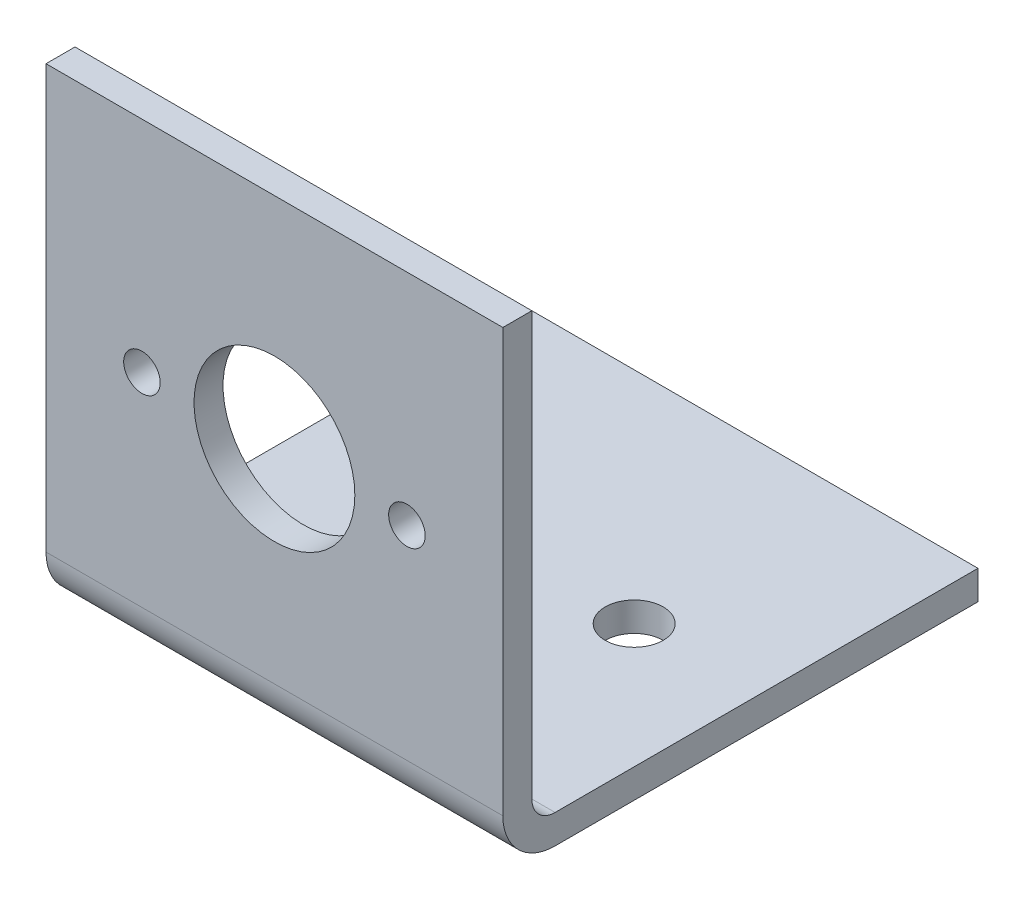
from build123d import *

# Parameters (mm, degrees)
BOSS_EXTRUDE1_DEPTH     = 50
FILLET1_R               = 2.54
FILLET2_R               = 5.715
SKETCH2_R               = 8.8
SKETCH2_R_2             = 2
CUT_EXTRUDE1_DEPTH      = 1
CUT_EXTRUDE1_DEPTH_BACK = 53
SKETCH4_R               = 3.175
CUT_EXTRUDE2_DEPTH      = 1
CUT_EXTRUDE2_DEPTH_BACK = 53


with BuildPart() as part:
    # Sketch1 → Boss-Extrude1 (new body)
    with BuildSketch(Plane(origin=(0, 0, 0), x_dir=(0, 0, -1), z_dir=(1, 0, 0))):
        Polygon((0, 0), (0, -52), (52, -52), (52, -48.825), (3.175, -48.825), (3.175, 0), align=None)
    extrude(amount=BOSS_EXTRUDE1_DEPTH)

    # Fillet1
    fillet1_edges = [part.edges().sort_by_distance(p)[0] for p in [
        (25, -48.825, -3.175),
    ]]
    fillet(fillet1_edges, radius=FILLET1_R)

    # Fillet2
    fillet2_edges = [part.edges().sort_by_distance(p)[0] for p in [
        (25, -52, 0),
    ]]
    fillet(fillet2_edges, radius=FILLET2_R)

    # Sketch2 → Cut-Extrude1 (cut, two sides)
    with BuildSketch(Plane.XY) as cut_extrude1_sk:
        with Locations((25, -24)):
            Circle(SKETCH2_R)
        with Locations((10.5, -24)):
            Circle(SKETCH2_R_2)
        with Locations((39.5, -24)):
            Circle(SKETCH2_R_2)
    extrude(amount=CUT_EXTRUDE1_DEPTH, mode=Mode.SUBTRACT)
    extrude(cut_extrude1_sk.sketch, amount=-CUT_EXTRUDE1_DEPTH_BACK, mode=Mode.SUBTRACT)

    # Sketch4 → Cut-Extrude2 (cut, two sides)
    with BuildSketch(Plane.XZ.offset(52)) as cut_extrude2_sk:
        with Locations((13.57, -27.94)):
            Circle(SKETCH4_R)
        with Locations((36.43, -27.94)):
            Circle(SKETCH4_R)
        with Locations((25, -12.7)):
            Circle(SKETCH4_R)
    extrude(amount=CUT_EXTRUDE2_DEPTH, mode=Mode.SUBTRACT)
    extrude(cut_extrude2_sk.sketch, amount=-CUT_EXTRUDE2_DEPTH_BACK, mode=Mode.SUBTRACT)


solid = part.part
